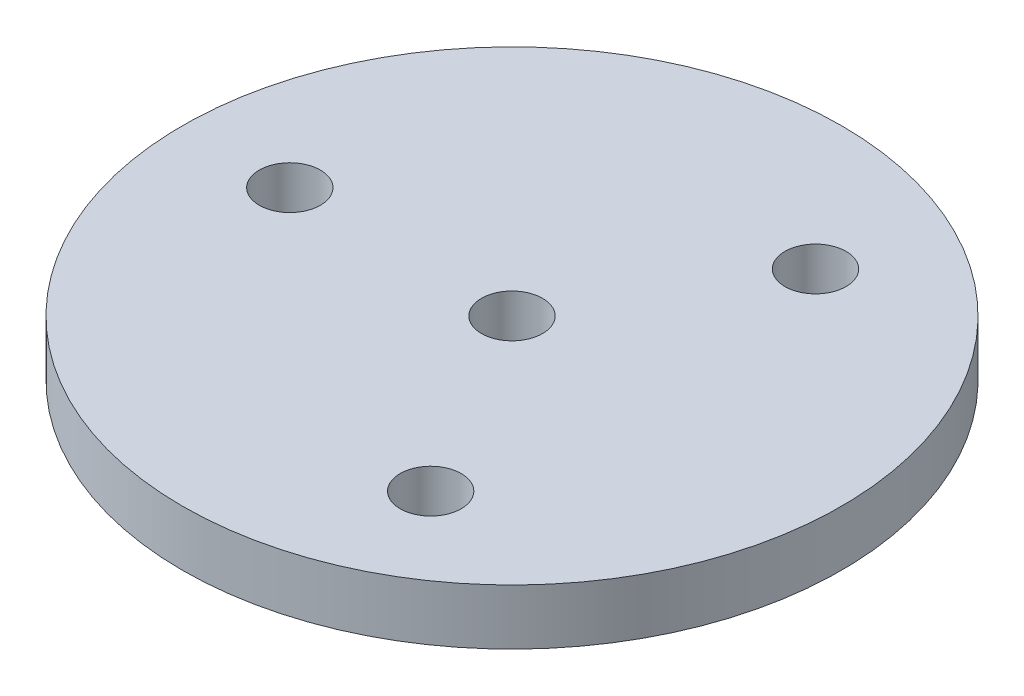
from build123d import *

# Parameters (mm, degrees)
SKIZZE1_W                       = 16.8
SKIZZE1_H                       = 3
SKIZZE2_R                       = 1
SCHNITT_LINEAR_AUSTRAGEN1_DEPTH = 26.351134097
KREISMUSTER1_COUNT              = 3
M4_GEWINDEBOHRUNG1_D            = 3.3


with BuildPart() as part:
    # Skizze1 → Rotation1 (revolve)
    with BuildSketch(Plane(origin=(0, 0, 0), x_dir=(0, 0, -1), z_dir=(1, 0, 0))):
        with Locations((-9.4, 1.5)):
            Rectangle(SKIZZE1_W, SKIZZE1_H)
    revolve(axis=Axis((0, 0, 0), (0, 1, 0)))

    # Skizze2 → Schnitt-Linear austragen1 (cut, through all)
    with BuildSketch(Plane(origin=(0, 3, 0), x_dir=(1, 0, 0), z_dir=(0, 1, 0))):
        with Locations((-12, 0)):
            Circle(SKIZZE2_R)
    schnitt_linear_austragen1 = extrude(amount=-SCHNITT_LINEAR_AUSTRAGEN1_DEPTH, mode=Mode.SUBTRACT)

    # Kreismuster1: Schnitt-Linear austragen1 ×3 about axis
    kreismuster1_axis = Axis((0, 3, 0), (0, -1, 0))
    for i in range(1, KREISMUSTER1_COUNT):
        add(schnitt_linear_austragen1.rotate(kreismuster1_axis, i * 360 / KREISMUSTER1_COUNT), mode=Mode.SUBTRACT)

    # M4 Gewindebohrung1 (through all)
    with Locations(Plane(origin=(0, 3, 0), x_dir=(1, 0, 0), z_dir=(0, 1, 0))):
        with Locations((0, 0), (6, 10.392304845), (-12, 0), (6, -10.392304845)):
            Hole(M4_GEWINDEBOHRUNG1_D / 2)


solid = part.part
